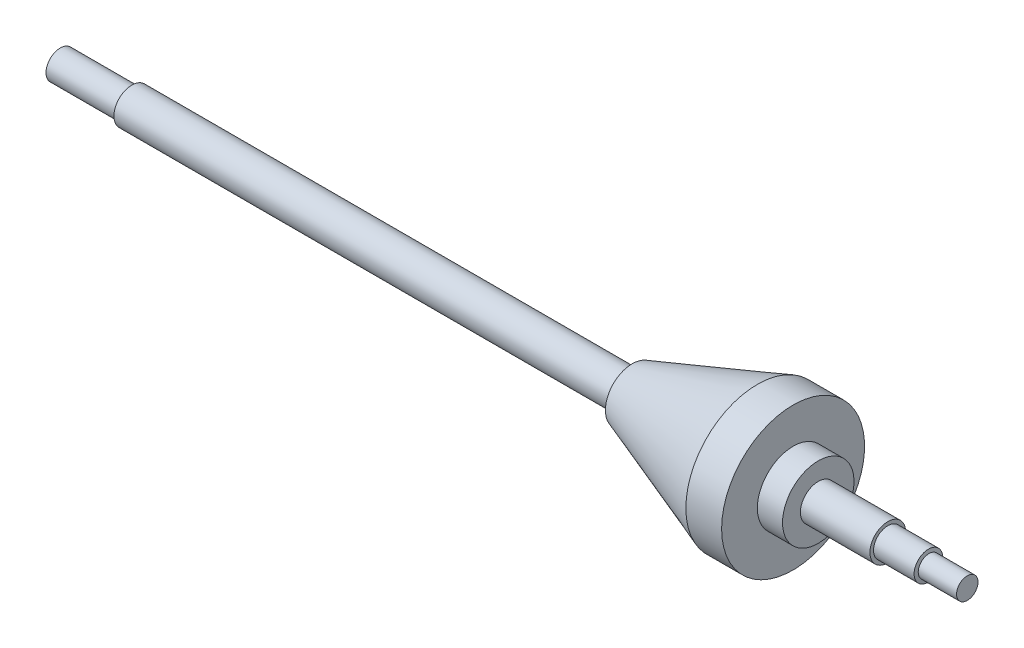
from build123d import *


with BuildPart() as part:
    # Sketch1 → Revolve1 (revolve)
    with BuildSketch(Plane(origin=(0, 0, 0), x_dir=(1, 0, 0), z_dir=(0, 1, 0))):
        Polygon((0, 0), (0, -4), (20, -4), (20, -5), (160, -5), (160, -7.5), (195, -20), (205, -20), (205, -10), (212.040983142, -10), (212.040983142, -5), (231.496163683, -5), (231.496163683, -4), (242.851662404, -4), (243.006172547, -3), (253.734015345, -3), (253.734015345, 0), align=None)
    revolve(axis=Axis((0, 0, 0), (1, 0, 0)))


solid = part.part
